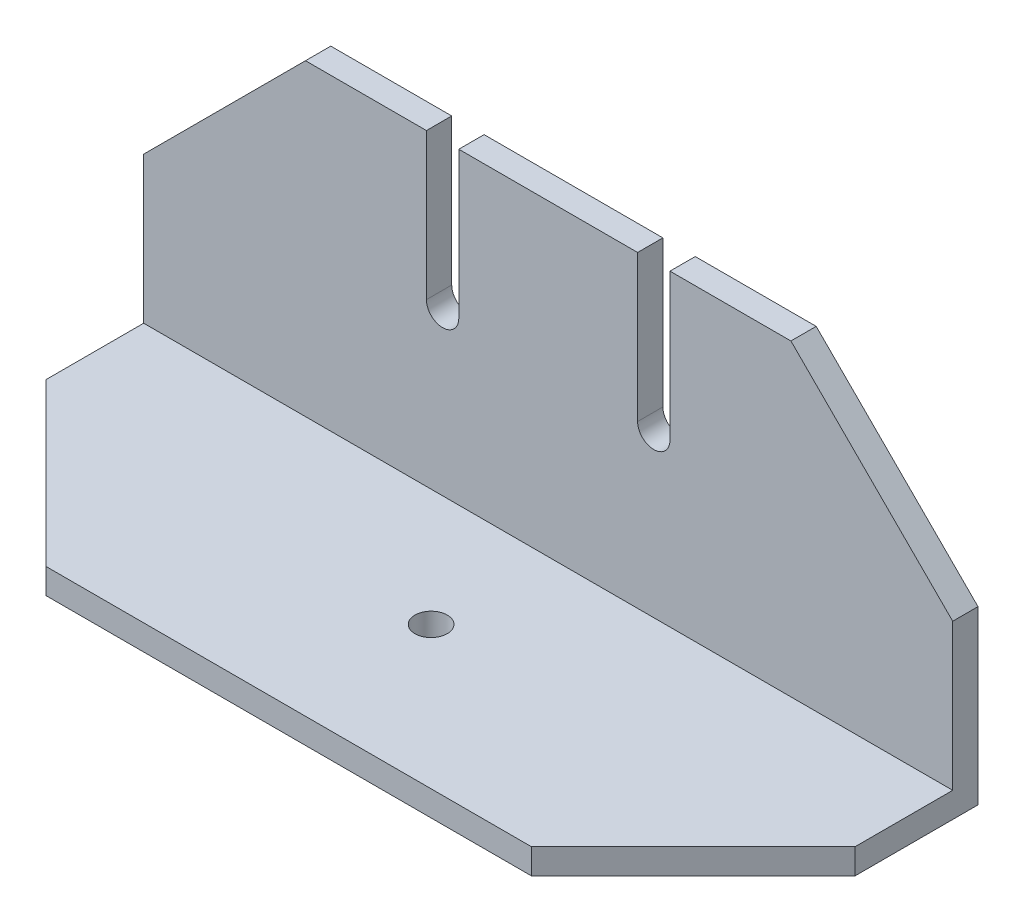
from build123d import *

# Parameters (mm, degrees)
EXTRUDE_THIN1_DEPTH = 100
CUT_EXTRUDE1_DEPTH  = 36.197996578
CHAMFER1_SIZE       = 20
CHAMFER2_SIZE       = 20
SKETCH3_R           = 2
CUT_EXTRUDE2_DEPTH  = 42.225


with BuildPart() as part:
    # Sketch1 → Extrude-Thin1 (new body)
    with BuildSketch(Plane(origin=(0, 0, 0), x_dir=(0, 0, -1), z_dir=(1, 0, 0))):
        Polygon((0, 0), (32.072996578, 0), (32.072996578, 38.1), (35.197996578, 38.1), (35.197996578, -3.125), (0, -3.125), align=None)
    extrude(amount=EXTRUDE_THIN1_DEPTH)

    # Sketch2 → Cut-Extrude1 (cut, through all)
    with BuildSketch(Plane(origin=(0, 0, -35.197996578), x_dir=(-1, 0, 0), z_dir=(0, 0, -1))):
        with BuildLine():
            Line((-61.05, 20), (-61.05, 38.1))
            Line((-61.05, 38.1), (-65.05, 38.1))
            Line((-65.05, 38.1), (-65.05, 20))
            ThreePointArc((-65.05, 20), (-63.05, 18), (-61.05, 20))
        make_face()
        with BuildLine():
            Line((-38.95, 20), (-38.95, 38.1))
            Line((-38.95, 38.1), (-34.95, 38.1))
            Line((-34.95, 38.1), (-34.95, 20))
            ThreePointArc((-34.95, 20), (-36.95, 18), (-38.95, 20))
        make_face()
    extrude(amount=-CUT_EXTRUDE1_DEPTH, mode=Mode.SUBTRACT)

    # Chamfer1
    chamfer1_edges = [part.edges().sort_by_distance(p)[0] for p in [
        (0, 38.1, -33.635496578),
        (100, 38.1, -33.635496578),
    ]]
    chamfer(chamfer1_edges, length=CHAMFER1_SIZE)

    # Chamfer2
    chamfer2_edges = [part.edges().sort_by_distance(p)[0] for p in [
        (100, -1.5625, 0),
        (0, -1.5625, 0),
    ]]
    chamfer(chamfer2_edges, length=CHAMFER2_SIZE)

    # Sketch3 → Cut-Extrude2 (cut, through all)
    with BuildSketch(Plane.XZ.offset(3.125)):
        with Locations(Location((50, -17.598998289, 0), (0, 0, 270))):  # turned: the seam where the file's is
            Circle(SKETCH3_R)
    extrude(amount=-CUT_EXTRUDE2_DEPTH, mode=Mode.SUBTRACT)


solid = part.part
